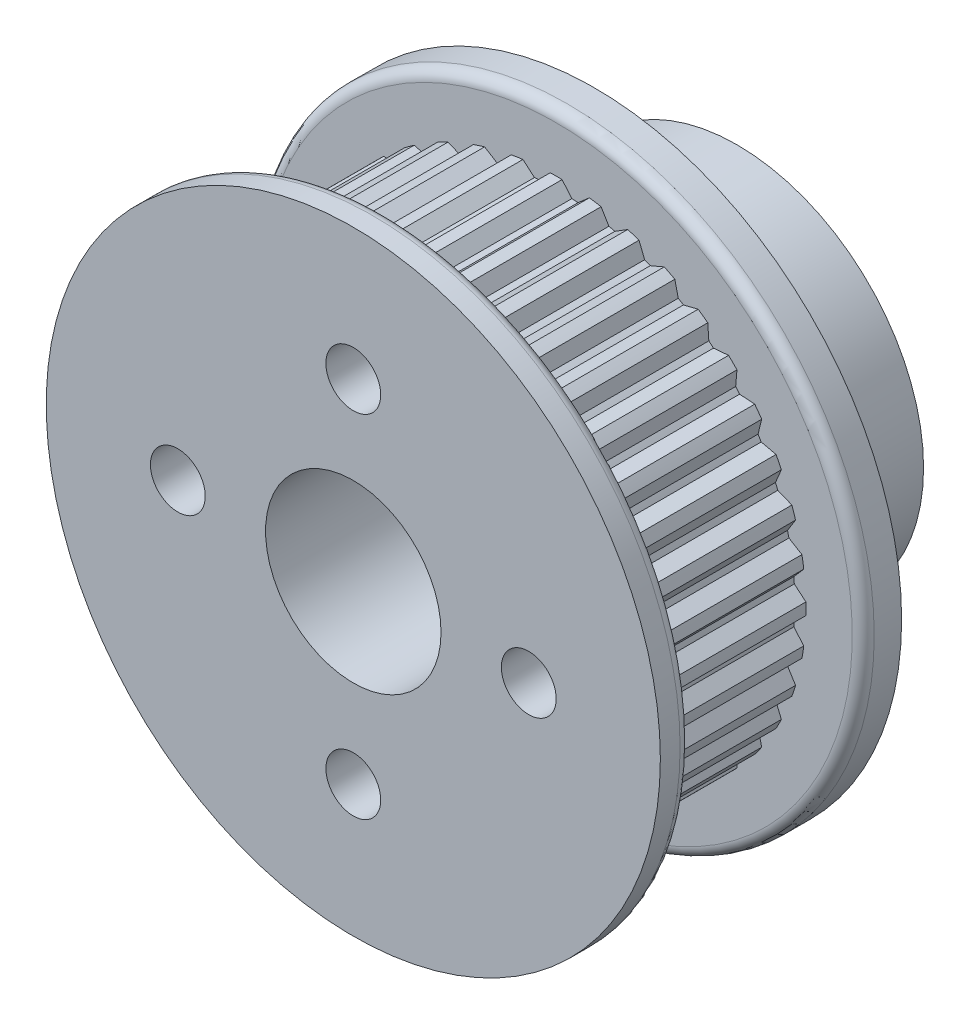
from build123d import *

# Parameters (mm, degrees)
SKETCH2_R          = 15.676956524
CUT_EXTRUDE1_DEPTH = 7.85
FILLET1_R          = 0.5
SKETCH3_R          = 1.25
CUT_EXTRUDE2_DEPTH = 9


with BuildPart() as part:
    # Sketch1 → Revolve1 (revolve)
    with BuildSketch(Plane(origin=(0, 0, 0), x_dir=(0, 0, -1), z_dir=(1, 0, 0))):
        Polygon((0, 4), (0, 8.5), (0, 14), (1.4, 14), (1.4, 11.39), (9.25, 11.39), (9.25, 14), (11, 14), (11, 8.5), (17.5, 8.5), (17.5, 4), align=None)
    revolve(axis=Axis((0, 0, 0), (0, 0, -1)))

    # Sketch2 → Cut-Extrude1 (cut)
    with BuildSketch(Plane(origin=(0, 0, -1.4), x_dir=(-1, 0, 0), z_dir=(0, 0, -1))):
        Circle(SKETCH2_R)
        with BuildLine():
            Line((0.27, 11.386799375), (0.714989557, 10.856481471))
            ThreePointArc((0.714989557, 10.856481471), (0.853634962, 10.846460591), (0.992141022, 10.834669178))
            Line((0.992141022, 10.834669178), (1.514612017, 11.288846285))
            ThreePointArc((1.514612017, 11.288846285), (1.648316086, 11.270100003), (1.781788557, 11.249770199))
            ThreePointArc((1.781788557, 11.249770199), (1.915010674, 11.22785973), (2.047963721, 11.204371674))
            Line((2.047963721, 11.204371674), (2.404514721, 10.61097116))
            ThreePointArc((2.404514721, 10.61097116), (2.539885559, 10.579384734), (2.674841796, 10.546071371))
            Line((2.674841796, 10.546071371), (3.261929259, 10.912924334))
            ThreePointArc((3.261929259, 10.912924334), (3.391054645, 10.873492925), (3.519703566, 10.832533721))
            ThreePointArc((3.519703566, 10.832533721), (3.647857946, 10.790052475), (3.775499778, 10.746055157))
            Line((3.775499778, 10.746055157), (4.034832751, 10.104183523))
            ThreePointArc((4.034832751, 10.104183523), (4.163595744, 10.051809314), (4.291679088, 9.997794287))
            Line((4.291679088, 9.997794287), (4.928926977, 10.268289967))
            ThreePointArc((4.928926977, 10.268289967), (5.050294184, 10.209144364), (5.170951792, 10.148564311))
            ThreePointArc((5.170951792, 10.148564311), (5.290882848, 10.086558317), (5.4100705, 10.023135098))
            Line((5.4100705, 10.023135098), (5.565799809, 9.348597354))
            ThreePointArc((5.565799809, 9.348597354), (5.684784384, 9.276724988), (5.802840998, 9.203338327))
            Line((5.802840998, 9.203338327), (6.474558155, 9.370816224))
            ThreePointArc((6.474558155, 9.370816224), (6.585178719, 9.293412787), (6.694874024, 9.214703566))
            ThreePointArc((6.694874024, 9.214703566), (6.803628655, 9.134699619), (6.911427332, 9.053412188))
            Line((6.911427332, 9.053412188), (6.959718403, 8.362817692))
            ThreePointArc((6.959718403, 8.362817692), (7.065994766, 8.273216906), (7.171117704, 8.182265633))
            Line((7.171117704, 8.182265633), (7.860764223, 8.242601885))
            ThreePointArc((7.860764223, 8.242601885), (7.9579143, 8.148846544), (8.053946238, 8.053946238))
            ThreePointArc((8.053946238, 8.053946238), (8.148846544, 7.9579143), (8.242601885, 7.860764223))
            Line((8.242601885, 7.860764223), (8.182265633, 7.171117704))
            ThreePointArc((8.182265633, 7.171117704), (8.273216906, 7.065994766), (8.362817692, 6.959718403))
            Line((8.362817692, 6.959718403), (9.053412188, 6.911427332))
            ThreePointArc((9.053412188, 6.911427332), (9.134699619, 6.803628655), (9.214703566, 6.694874024))
            ThreePointArc((9.214703566, 6.694874024), (9.293412787, 6.585178719), (9.370816224, 6.474558155))
            Line((9.370816224, 6.474558155), (9.203338327, 5.802840998))
            ThreePointArc((9.203338327, 5.802840998), (9.276724988, 5.684784384), (9.348597354, 5.565799809))
            Line((9.348597354, 5.565799809), (10.023135098, 5.4100705))
            ThreePointArc((10.023135098, 5.4100705), (10.086558317, 5.290882848), (10.148564311, 5.170951792))
            ThreePointArc((10.148564311, 5.170951792), (10.209144364, 5.050294184), (10.268289967, 4.928926977))
            Line((10.268289967, 4.928926977), (9.997794287, 4.291679088))
            ThreePointArc((9.997794287, 4.291679088), (10.051809314, 4.163595744), (10.104183523, 4.034832751))
            Line((10.104183523, 4.034832751), (10.746055157, 3.775499778))
            ThreePointArc((10.746055157, 3.775499778), (10.790052475, 3.647857946), (10.832533721, 3.519703566))
            ThreePointArc((10.832533721, 3.519703566), (10.873492925, 3.391054645), (10.912924334, 3.261929259))
            Line((10.912924334, 3.261929259), (10.546071371, 2.674841796))
            ThreePointArc((10.546071371, 2.674841796), (10.579384734, 2.539885559), (10.61097116, 2.404514721))
            Line((10.61097116, 2.404514721), (11.204371674, 2.047963721))
            ThreePointArc((11.204371674, 2.047963721), (11.22785973, 1.915010674), (11.249770199, 1.781788557))
            ThreePointArc((11.249770199, 1.781788557), (11.270100003, 1.648316086), (11.288846285, 1.514612017))
            Line((11.288846285, 1.514612017), (10.834669178, 0.992141022))
            ThreePointArc((10.834669178, 0.992141022), (10.846460591, 0.853634962), (10.856481471, 0.714989557))
            Line((10.856481471, 0.714989557), (11.386799375, 0.27))
            ThreePointArc((11.386799375, 0.27), (11.389199816, 0.135009485), (11.39, 0))
            ThreePointArc((11.39, 0), (11.389199816, -0.135009485), (11.386799375, -0.27))
            Line((11.386799375, -0.27), (10.856481471, -0.714989557))
            ThreePointArc((10.856481471, -0.714989557), (10.846460591, -0.853634962), (10.834669178, -0.992141022))
            Line((10.834669178, -0.992141022), (11.288846285, -1.514612017))
            ThreePointArc((11.288846285, -1.514612017), (11.270100003, -1.648316086), (11.249770199, -1.781788557))
            ThreePointArc((11.249770199, -1.781788557), (11.22785973, -1.915010674), (11.204371674, -2.047963721))
            Line((11.204371674, -2.047963721), (10.61097116, -2.404514721))
            ThreePointArc((10.61097116, -2.404514721), (10.579384734, -2.539885559), (10.546071371, -2.674841796))
            Line((10.546071371, -2.674841796), (10.912924334, -3.261929259))
            ThreePointArc((10.912924334, -3.261929259), (10.873492925, -3.391054645), (10.832533721, -3.519703566))
            ThreePointArc((10.832533721, -3.519703566), (10.790052475, -3.647857946), (10.746055157, -3.775499778))
            Line((10.746055157, -3.775499778), (10.104183523, -4.034832751))
            ThreePointArc((10.104183523, -4.034832751), (10.051809314, -4.163595744), (9.997794287, -4.291679088))
            Line((9.997794287, -4.291679088), (10.268289967, -4.928926977))
            ThreePointArc((10.268289967, -4.928926977), (10.209144364, -5.050294184), (10.148564311, -5.170951792))
            ThreePointArc((10.148564311, -5.170951792), (10.086558317, -5.290882848), (10.023135098, -5.4100705))
            Line((10.023135098, -5.4100705), (9.348597354, -5.565799809))
            ThreePointArc((9.348597354, -5.565799809), (9.276724988, -5.684784384), (9.203338327, -5.802840998))
            Line((9.203338327, -5.802840998), (9.370816224, -6.474558155))
            ThreePointArc((9.370816224, -6.474558155), (9.293412787, -6.585178719), (9.214703566, -6.694874024))
            ThreePointArc((9.214703566, -6.694874024), (9.134699619, -6.803628655), (9.053412188, -6.911427332))
            Line((9.053412188, -6.911427332), (8.362817692, -6.959718403))
            ThreePointArc((8.362817692, -6.959718403), (8.273216906, -7.065994766), (8.182265633, -7.171117704))
            Line((8.182265633, -7.171117704), (8.242601885, -7.860764223))
            ThreePointArc((8.242601885, -7.860764223), (8.148846544, -7.9579143), (8.053946238, -8.053946238))
            ThreePointArc((8.053946238, -8.053946238), (7.9579143, -8.148846544), (7.860764223, -8.242601885))
            Line((7.860764223, -8.242601885), (7.171117704, -8.182265633))
            ThreePointArc((7.171117704, -8.182265633), (7.065994766, -8.273216906), (6.959718403, -8.362817692))
            Line((6.959718403, -8.362817692), (6.911427332, -9.053412188))
            ThreePointArc((6.911427332, -9.053412188), (6.803628655, -9.134699619), (6.694874024, -9.214703566))
            ThreePointArc((6.694874024, -9.214703566), (6.585178719, -9.293412787), (6.474558155, -9.370816224))
            Line((6.474558155, -9.370816224), (5.802840998, -9.203338327))
            ThreePointArc((5.802840998, -9.203338327), (5.684784384, -9.276724988), (5.565799809, -9.348597354))
            Line((5.565799809, -9.348597354), (5.4100705, -10.023135098))
            ThreePointArc((5.4100705, -10.023135098), (5.290882848, -10.086558317), (5.170951792, -10.148564311))
            ThreePointArc((5.170951792, -10.148564311), (5.050294184, -10.209144364), (4.928926977, -10.268289967))
            Line((4.928926977, -10.268289967), (4.291679088, -9.997794287))
            ThreePointArc((4.291679088, -9.997794287), (4.163595744, -10.051809314), (4.034832751, -10.104183523))
            Line((4.034832751, -10.104183523), (3.775499778, -10.746055157))
            ThreePointArc((3.775499778, -10.746055157), (3.647857946, -10.790052475), (3.519703566, -10.832533721))
            ThreePointArc((3.519703566, -10.832533721), (3.391054645, -10.873492925), (3.261929259, -10.912924334))
            Line((3.261929259, -10.912924334), (2.674841796, -10.546071371))
            ThreePointArc((2.674841796, -10.546071371), (2.539885559, -10.579384734), (2.404514721, -10.61097116))
            Line((2.404514721, -10.61097116), (2.047963721, -11.204371674))
            ThreePointArc((2.047963721, -11.204371674), (1.915010674, -11.22785973), (1.781788557, -11.249770199))
            ThreePointArc((1.781788557, -11.249770199), (1.648316086, -11.270100003), (1.514612017, -11.288846285))
            Line((1.514612017, -11.288846285), (0.992141022, -10.834669178))
            ThreePointArc((0.992141022, -10.834669178), (0.853634962, -10.846460591), (0.714989557, -10.856481471))
            Line((0.714989557, -10.856481471), (0.27, -11.386799375))
            ThreePointArc((0.27, -11.386799375), (0.135009485, -11.389199816), (0, -11.39))
            ThreePointArc((0, -11.39), (-0.135009485, -11.389199816), (-0.27, -11.386799375))
            Line((-0.27, -11.386799375), (-0.714989557, -10.856481471))
            ThreePointArc((-0.714989557, -10.856481471), (-0.853634962, -10.846460591), (-0.992141022, -10.834669178))
            Line((-0.992141022, -10.834669178), (-1.514612017, -11.288846285))
            ThreePointArc((-1.514612017, -11.288846285), (-1.648316086, -11.270100003), (-1.781788557, -11.249770199))
            ThreePointArc((-1.781788557, -11.249770199), (-1.915010674, -11.22785973), (-2.047963721, -11.204371674))
            Line((-2.047963721, -11.204371674), (-2.404514721, -10.61097116))
            ThreePointArc((-2.404514721, -10.61097116), (-2.539885559, -10.579384734), (-2.674841796, -10.546071371))
            Line((-2.674841796, -10.546071371), (-3.261929259, -10.912924334))
            ThreePointArc((-3.261929259, -10.912924334), (-3.391054645, -10.873492925), (-3.519703566, -10.832533721))
            ThreePointArc((-3.519703566, -10.832533721), (-3.647857946, -10.790052475), (-3.775499778, -10.746055157))
            Line((-3.775499778, -10.746055157), (-4.034832751, -10.104183523))
            ThreePointArc((-4.034832751, -10.104183523), (-4.163595744, -10.051809314), (-4.291679088, -9.997794287))
            Line((-4.291679088, -9.997794287), (-4.928926977, -10.268289967))
            ThreePointArc((-4.928926977, -10.268289967), (-5.050294184, -10.209144364), (-5.170951792, -10.148564311))
            ThreePointArc((-5.170951792, -10.148564311), (-5.290882848, -10.086558317), (-5.4100705, -10.023135098))
            Line((-5.4100705, -10.023135098), (-5.565799809, -9.348597354))
            ThreePointArc((-5.565799809, -9.348597354), (-5.684784384, -9.276724988), (-5.802840998, -9.203338327))
            Line((-5.802840998, -9.203338327), (-6.474558155, -9.370816224))
            ThreePointArc((-6.474558155, -9.370816224), (-6.585178719, -9.293412787), (-6.694874024, -9.214703566))
            ThreePointArc((-6.694874024, -9.214703566), (-6.803628655, -9.134699619), (-6.911427332, -9.053412188))
            Line((-6.911427332, -9.053412188), (-6.959718403, -8.362817692))
            ThreePointArc((-6.959718403, -8.362817692), (-7.065994766, -8.273216906), (-7.171117704, -8.182265633))
            Line((-7.171117704, -8.182265633), (-7.860764223, -8.242601885))
            ThreePointArc((-7.860764223, -8.242601885), (-7.9579143, -8.148846544), (-8.053946238, -8.053946238))
            ThreePointArc((-8.053946238, -8.053946238), (-8.148846544, -7.9579143), (-8.242601885, -7.860764223))
            Line((-8.242601885, -7.860764223), (-8.182265633, -7.171117704))
            ThreePointArc((-8.182265633, -7.171117704), (-8.273216906, -7.065994766), (-8.362817692, -6.959718403))
            Line((-8.362817692, -6.959718403), (-9.053412188, -6.911427332))
            ThreePointArc((-9.053412188, -6.911427332), (-9.134699619, -6.803628655), (-9.214703566, -6.694874024))
            ThreePointArc((-9.214703566, -6.694874024), (-9.293412787, -6.585178719), (-9.370816224, -6.474558155))
            Line((-9.370816224, -6.474558155), (-9.203338327, -5.802840998))
            ThreePointArc((-9.203338327, -5.802840998), (-9.276724988, -5.684784384), (-9.348597354, -5.565799809))
            Line((-9.348597354, -5.565799809), (-10.023135098, -5.4100705))
            ThreePointArc((-10.023135098, -5.4100705), (-10.086558317, -5.290882848), (-10.148564311, -5.170951792))
            ThreePointArc((-10.148564311, -5.170951792), (-10.209144364, -5.050294184), (-10.268289967, -4.928926977))
            Line((-10.268289967, -4.928926977), (-9.997794287, -4.291679088))
            ThreePointArc((-9.997794287, -4.291679088), (-10.051809314, -4.163595744), (-10.104183523, -4.034832751))
            Line((-10.104183523, -4.034832751), (-10.746055157, -3.775499778))
            ThreePointArc((-10.746055157, -3.775499778), (-10.790052475, -3.647857946), (-10.832533721, -3.519703566))
            ThreePointArc((-10.832533721, -3.519703566), (-10.873492925, -3.391054645), (-10.912924334, -3.261929259))
            Line((-10.912924334, -3.261929259), (-10.546071371, -2.674841796))
            ThreePointArc((-10.546071371, -2.674841796), (-10.579384734, -2.539885559), (-10.61097116, -2.404514721))
            Line((-10.61097116, -2.404514721), (-11.204371674, -2.047963721))
            ThreePointArc((-11.204371674, -2.047963721), (-11.22785973, -1.915010674), (-11.249770199, -1.781788557))
            ThreePointArc((-11.249770199, -1.781788557), (-11.270100003, -1.648316086), (-11.288846285, -1.514612017))
            Line((-11.288846285, -1.514612017), (-10.834669178, -0.992141022))
            ThreePointArc((-10.834669178, -0.992141022), (-10.846460591, -0.853634962), (-10.856481471, -0.714989557))
            Line((-10.856481471, -0.714989557), (-11.386799375, -0.27))
            ThreePointArc((-11.386799375, -0.27), (-11.389199816, -0.135009485), (-11.39, 0))
            ThreePointArc((-11.39, 0), (-11.389199816, 0.135009485), (-11.386799375, 0.27))
            Line((-11.386799375, 0.27), (-10.856481471, 0.714989557))
            ThreePointArc((-10.856481471, 0.714989557), (-10.846460591, 0.853634962), (-10.834669178, 0.992141022))
            Line((-10.834669178, 0.992141022), (-11.288846285, 1.514612017))
            ThreePointArc((-11.288846285, 1.514612017), (-11.270100003, 1.648316086), (-11.249770199, 1.781788557))
            ThreePointArc((-11.249770199, 1.781788557), (-11.22785973, 1.915010674), (-11.204371674, 2.047963721))
            Line((-11.204371674, 2.047963721), (-10.61097116, 2.404514721))
            ThreePointArc((-10.61097116, 2.404514721), (-10.579384734, 2.539885559), (-10.546071371, 2.674841796))
            Line((-10.546071371, 2.674841796), (-10.912924334, 3.261929259))
            ThreePointArc((-10.912924334, 3.261929259), (-10.873492925, 3.391054645), (-10.832533721, 3.519703566))
            ThreePointArc((-10.832533721, 3.519703566), (-10.790052475, 3.647857946), (-10.746055157, 3.775499778))
            Line((-10.746055157, 3.775499778), (-10.104183523, 4.034832751))
            ThreePointArc((-10.104183523, 4.034832751), (-10.051809314, 4.163595744), (-9.997794287, 4.291679088))
            Line((-9.997794287, 4.291679088), (-10.268289967, 4.928926977))
            ThreePointArc((-10.268289967, 4.928926977), (-10.209144364, 5.050294184), (-10.148564311, 5.170951792))
            ThreePointArc((-10.148564311, 5.170951792), (-10.086558317, 5.290882848), (-10.023135098, 5.4100705))
            Line((-10.023135098, 5.4100705), (-9.348597354, 5.565799809))
            ThreePointArc((-9.348597354, 5.565799809), (-9.276724988, 5.684784384), (-9.203338327, 5.802840998))
            Line((-9.203338327, 5.802840998), (-9.370816224, 6.474558155))
            ThreePointArc((-9.370816224, 6.474558155), (-9.293412787, 6.585178719), (-9.214703566, 6.694874024))
            ThreePointArc((-9.214703566, 6.694874024), (-9.134699619, 6.803628655), (-9.053412188, 6.911427332))
            Line((-9.053412188, 6.911427332), (-8.362817692, 6.959718403))
            ThreePointArc((-8.362817692, 6.959718403), (-8.273216906, 7.065994766), (-8.182265633, 7.171117704))
            Line((-8.182265633, 7.171117704), (-8.242601885, 7.860764223))
            ThreePointArc((-8.242601885, 7.860764223), (-8.148846544, 7.9579143), (-8.053946238, 8.053946238))
            ThreePointArc((-8.053946238, 8.053946238), (-7.9579143, 8.148846544), (-7.860764223, 8.242601885))
            Line((-7.860764223, 8.242601885), (-7.171117704, 8.182265633))
            ThreePointArc((-7.171117704, 8.182265633), (-7.065994766, 8.273216906), (-6.959718403, 8.362817692))
            Line((-6.959718403, 8.362817692), (-6.911427332, 9.053412188))
            ThreePointArc((-6.911427332, 9.053412188), (-6.803628655, 9.134699619), (-6.694874024, 9.214703566))
            ThreePointArc((-6.694874024, 9.214703566), (-6.585178719, 9.293412787), (-6.474558155, 9.370816224))
            Line((-6.474558155, 9.370816224), (-5.802840998, 9.203338327))
            ThreePointArc((-5.802840998, 9.203338327), (-5.684784384, 9.276724988), (-5.565799809, 9.348597354))
            Line((-5.565799809, 9.348597354), (-5.4100705, 10.023135098))
            ThreePointArc((-5.4100705, 10.023135098), (-5.290882848, 10.086558317), (-5.170951792, 10.148564311))
            ThreePointArc((-5.170951792, 10.148564311), (-5.050294184, 10.209144364), (-4.928926977, 10.268289967))
            Line((-4.928926977, 10.268289967), (-4.291679088, 9.997794287))
            ThreePointArc((-4.291679088, 9.997794287), (-4.163595744, 10.051809314), (-4.034832751, 10.104183523))
            Line((-4.034832751, 10.104183523), (-3.775499778, 10.746055157))
            ThreePointArc((-3.775499778, 10.746055157), (-3.647857946, 10.790052475), (-3.519703566, 10.832533721))
            ThreePointArc((-3.519703566, 10.832533721), (-3.391054645, 10.873492925), (-3.261929259, 10.912924334))
            Line((-3.261929259, 10.912924334), (-2.674841796, 10.546071371))
            ThreePointArc((-2.674841796, 10.546071371), (-2.539885559, 10.579384734), (-2.404514721, 10.61097116))
            Line((-2.404514721, 10.61097116), (-2.047963721, 11.204371674))
            ThreePointArc((-2.047963721, 11.204371674), (-1.915010674, 11.22785973), (-1.781788557, 11.249770199))
            ThreePointArc((-1.781788557, 11.249770199), (-1.648316086, 11.270100003), (-1.514612017, 11.288846285))
            Line((-1.514612017, 11.288846285), (-0.992141022, 10.834669178))
            ThreePointArc((-0.992141022, 10.834669178), (-0.853634962, 10.846460591), (-0.714989557, 10.856481471))
            Line((-0.714989557, 10.856481471), (-0.27, 11.386799375))
            ThreePointArc((-0.27, 11.386799375), (-0.135009485, 11.389199816), (0, 11.39))
            ThreePointArc((0, 11.39), (0.135009485, 11.389199816), (0.27, 11.386799375))
        make_face(mode=Mode.SUBTRACT)
    extrude(amount=CUT_EXTRUDE1_DEPTH, mode=Mode.SUBTRACT)

    # Fillet1
    fillet1_edges = [part.edges().sort_by_distance(p)[0] for p in [
        (0, -14, -1.4),
        (0, -14, -9.25),
    ]]
    fillet(fillet1_edges, radius=FILLET1_R)

    # Sketch3 → Cut-Extrude2 (cut)
    with BuildSketch(Plane.XY):
        with Locations((0, 8)):
            Circle(SKETCH3_R)
        with Locations((8, 0)):
            Circle(SKETCH3_R)
        with Locations((0, -8)):
            Circle(SKETCH3_R)
        with Locations((-8, 0)):
            Circle(SKETCH3_R)
    extrude(amount=-CUT_EXTRUDE2_DEPTH, mode=Mode.SUBTRACT)


solid = part.part
